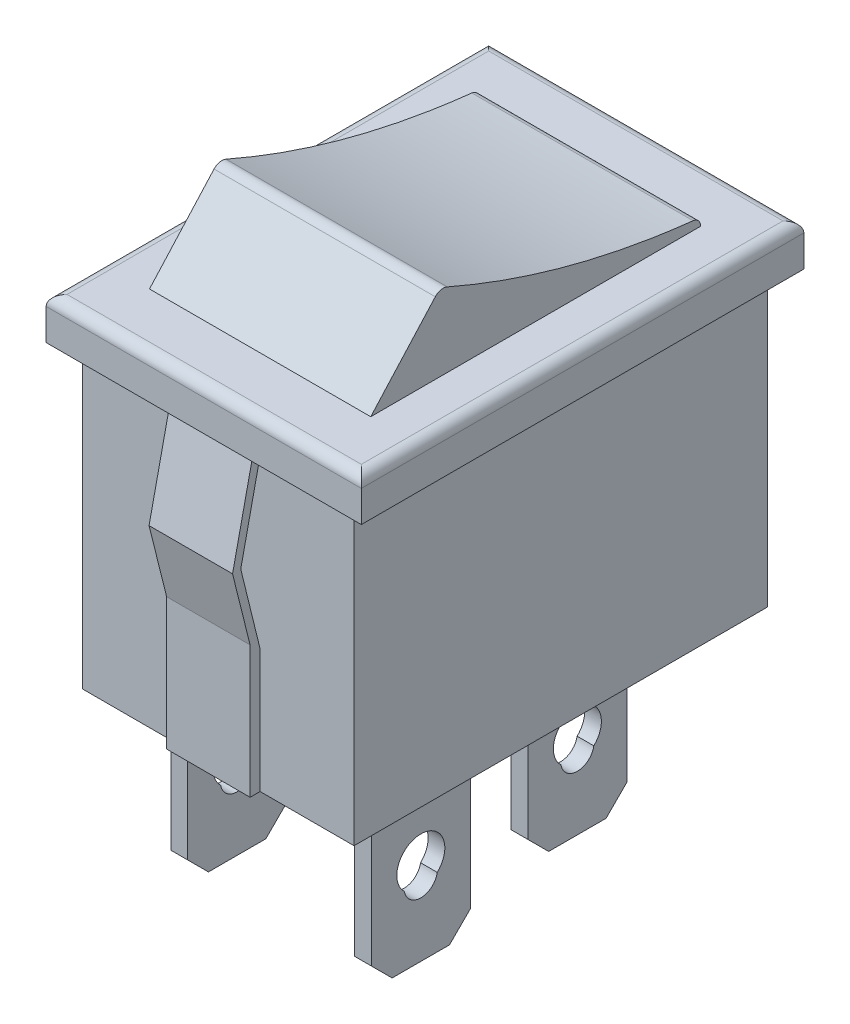
from build123d import *

# Parameters (mm, degrees)
SKETCH1_W                  = 13
SKETCH1_H                  = 19.8
BOSS_EXTRUDE1_DEPTH        = 14.2
SKETCH2_W                  = 15.1
SKETCH2_H                  = 21.2
BOSS_EXTRUDE2_DEPTH        = 2
FILLET1_R                  = 0.5
SKETCH3_W                  = 10.6
SKETCH3_H                  = 15.8
BOSS_EXTRUDE3_DEPTH        = 3.7
CUT_EXTRUDE1_DEPTH         = 3.25
CUT_EXTRUDE1_DEPTH_BACK    = 13.85
FILLET2_R                  = 0.5
FILLET3_R                  = 0.4
BOSS_EXTRUDE4_DEPTH        = 2
BOSS_EXTRUDE4_DEPTH_BACK   = 2
BOSS_EXTRUDE4_2_DEPTH      = 2
BOSS_EXTRUDE4_2_DEPTH_BACK = 2
SKETCH9_W                  = 0.8
SKETCH9_H                  = 4.75
BOSS_EXTRUDE5_DEPTH        = 8.1
CHAMFER1_SIZE              = 1
CUT_EXTRUDE2_DEPTH         = 13.35


with BuildPart() as part:
    # Sketch1 → Boss-Extrude1 (new body)
    with BuildSketch(Plane(origin=(0, 0, 0), x_dir=(1, 0, 0), z_dir=(0, 1, 0))):
        Rectangle(SKETCH1_W, SKETCH1_H)
    extrude(amount=BOSS_EXTRUDE1_DEPTH)

    # Sketch2 → Boss-Extrude2 (add)
    with BuildSketch(Plane(origin=(0, 14.2, 0), x_dir=(1, 0, 0), z_dir=(0, 1, 0))):
        Rectangle(SKETCH2_W, SKETCH2_H)
    extrude(amount=BOSS_EXTRUDE2_DEPTH)

    # Fillet1
    fillet1_edges = [part.edges().sort_by_distance(p)[0] for p in [
        (7.55, 16.2, 0),
        (0, 16.2, -10.6),
        (-7.55, 16.2, 0),
        (0, 16.2, 10.6),
    ]]
    fillet(fillet1_edges, radius=FILLET1_R)

    # Sketch3 → Boss-Extrude3 (add)
    with BuildSketch(Plane(origin=(0, 16.2, 0), x_dir=(1, 0, 0), z_dir=(0, 1, 0))):
        Rectangle(SKETCH3_W, SKETCH3_H)
    extrude(amount=BOSS_EXTRUDE3_DEPTH)

    # Sketch4 → Cut-Extrude1 (cut, two sides)
    with BuildSketch(Plane(origin=(5.3, 0, 0), x_dir=(0, 0, -1), z_dir=(1, 0, 0))) as cut_extrude1_sk:
        Polygon((-7.9, 19.9), (-7.9, 16.2), (-4.563876161, 19.9), align=None)
        with BuildLine():
            Line((7.9, 19.9), (-4.563876161, 19.9))
            add(Edge.make_bspline(
                [(-4.563876161, 19.9), (1.403607579, 17.21890735), (7.9, 16.574072903)],
                knots=[0, 0, 0, 1, 1, 1], degree=2))
            Line((7.9, 16.574072903), (7.9, 19.9))
        make_face()
    extrude(amount=CUT_EXTRUDE1_DEPTH, mode=Mode.SUBTRACT)
    extrude(cut_extrude1_sk.sketch, amount=-CUT_EXTRUDE1_DEPTH_BACK, mode=Mode.SUBTRACT)

    # Fillet2
    fillet2_edges = [part.edges().sort_by_distance(p)[0] for p in [
        (0, 19.9, 4.563876161),
    ]]
    fillet(fillet2_edges, radius=FILLET2_R)

    # Fillet3
    fillet3_edges = [part.edges().sort_by_distance(p)[0] for p in [
        (0, 16.574072903, -7.9),
    ]]
    fillet(fillet3_edges, radius=FILLET3_R)

    # Sketch9 → Boss-Extrude5 (add)
    with BuildSketch(Plane.XZ):
        with Locations((-4.4, 5)):
            Rectangle(SKETCH9_W, SKETCH9_H)
        with Locations((-2.9, -4)):
            Rectangle(SKETCH9_W, SKETCH9_H)
        with Locations((2.9, -4)):
            Rectangle(SKETCH9_W, SKETCH9_H)
        with Locations((4.4, 5)):
            Rectangle(SKETCH9_W, SKETCH9_H)
    extrude(amount=BOSS_EXTRUDE5_DEPTH)

    # Chamfer1
    chamfer1_edges = [part.edges().sort_by_distance(p)[0] for p in [
        (-4.4, -8.1, 2.625),
        (-4.4, -8.1, 7.375),
        (-2.9, -8.1, -6.375),
        (-2.9, -8.1, -1.625),
        (2.9, -8.1, -1.625),
        (2.9, -8.1, -6.375),
        (4.4, -8.1, 7.375),
        (4.4, -8.1, 2.625),
    ]]
    chamfer(chamfer1_edges, length=CHAMFER1_SIZE)

    # Sketch10 → Cut-Extrude2 (cut, through all)
    with BuildSketch(Plane(origin=(4.8, 0, 0), x_dir=(0, 0, -1), z_dir=(1, 0, 0))):
        with BuildLine():
            ThreePointArc((-4.211904987, -4.798606273), (-5, -2.811106273), (-5.788095013, -4.798606273))
            ThreePointArc((-5.788095013, -4.798606273), (-5, -5.461106273), (-4.211904987, -4.798606273))
        make_face()
        with BuildLine():
            ThreePointArc((4.788095013, -4.798606273), (4, -2.811106273), (3.211904987, -4.798606273))
            ThreePointArc((3.211904987, -4.798606273), (4, -5.461106273), (4.788095013, -4.798606273))
        make_face()
    extrude(amount=-CUT_EXTRUDE2_DEPTH, mode=Mode.SUBTRACT)


with BuildPart() as body_2:
    # Sketch8 → Boss-Extrude4 (new body, two sides)
    with BuildSketch(Plane(origin=(0, 0, 0), x_dir=(0, 0, -1), z_dir=(1, 0, 0))) as boss_extrude4_sk:
        Polygon((-9.9, 13.934809719), (-10.290851987, 13.934809719), (-11.220244873, 9.692999395), (-10.379004118, 6.321166149), (-10.379004118, 0), (-9.9, 0), (-9.9, 5.917943641), (-10.827447629, 9.692999395), align=None)
    extrude(amount=BOSS_EXTRUDE4_DEPTH)
    extrude(boss_extrude4_sk.sketch, amount=-BOSS_EXTRUDE4_DEPTH_BACK)


with BuildPart() as body_3:
    # Sketch8 → Boss-Extrude4 2 (new body, two sides)
    with BuildSketch(Plane(origin=(0, 0, 0), x_dir=(0, 0, -1), z_dir=(1, 0, 0))) as boss_extrude4_2_sk:
        Polygon((10.379004118, 0), (10.379004118, 6.321166149), (11.220244873, 9.692999395), (10.290851987, 13.934809719), (9.9, 13.934809719), (10.827447629, 9.692999395), (9.9, 5.917943641), (9.9, 0), align=None)
    extrude(amount=BOSS_EXTRUDE4_2_DEPTH)
    extrude(boss_extrude4_2_sk.sketch, amount=-BOSS_EXTRUDE4_2_DEPTH_BACK)


solid = Compound([part.part, body_2.part, body_3.part])
